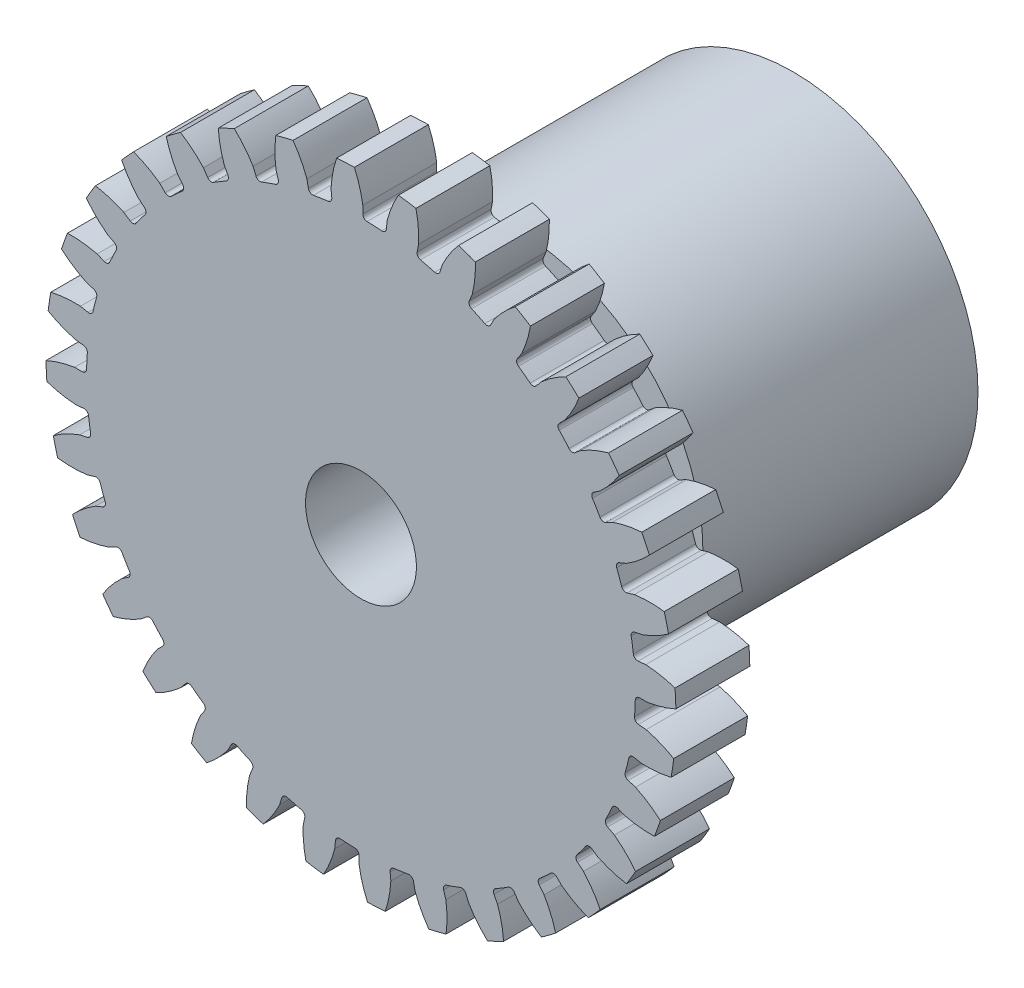
from build123d import *

# Parameters (mm, degrees)
SKETCH1_R                = 27.051
BOSS_EXTRUDE1_DEPTH      = 6.35
CUT_EXTRUDE1_DEPTH       = 7.35
FILLET1_R                = 0.37404675
CIRPATTERN1_COUNT        = 32
FILLET1_OF_CIRPATTERN1_R = 0.37404675
SKETCH5_R                = 11.1125
BOSS_EXTRUDE2_DEPTH      = 7.14375
SKETCH6_R                = 15.875
BOSS_EXTRUDE3_DEPTH      = 23.622
SKETCH7_R                = 4.7625
CUT_EXTRUDE2_DEPTH       = 38.1157501


with BuildPart() as part:
    # Sketch1 → Boss-Extrude1 (new body)
    with BuildSketch(Plane.XY):
        Circle(SKETCH1_R)
    extrude(amount=-BOSS_EXTRUDE1_DEPTH)

    # Sketch4 → Cut-Extrude1 (cut, through all)
    with BuildSketch(Plane.XY):
        with BuildLine():
            Line((0.160263574, 24.590427827), (0.160263574, 23.562717484))
            ThreePointArc((0.160263574, 23.562717484), (1.156197192, 23.534879386), (2.150063712, 23.464964643))
            Line((2.150063712, 23.464964643), (2.250797176, 24.487726256))
            add(Edge.make_bspline(
                [(5.408974443, 29.500900756), (2.99125855, 27.376376247), (2.250797176, 24.487726256)],
                knots=[0, 0, 0, 1, 1, 1], degree=2))
            ThreePointArc((5.408974443, 29.500900756), (1.471673918, 29.956540618), (-2.491327962, 29.889018634))
            add(Edge.make_bspline(
                [(-2.491327962, 29.889018634), (-0.293494388, 27.537746189), (0.160263574, 24.590427827)],
                knots=[0, 0, 0, 1, 1, 1], degree=2))
        make_face()
    cut_extrude1 = extrude(amount=-CUT_EXTRUDE1_DEPTH, mode=Mode.SUBTRACT)

    # Fillet1
    fillet1_edges = [part.edges().sort_by_distance(p)[0] for p in [
        (2.150063712, 23.464964643, -3.175),
        (0.160263574, 23.562717484, -3.175),
    ]]
    fillet(fillet1_edges, radius=FILLET1_R)

    # CirPattern1: Cut-Extrude1 ×32 about axis
    cirpattern1_axis = Axis((0, 0, -6.35), (0, 0, 1))
    for i in range(1, CIRPATTERN1_COUNT):
        add(cut_extrude1.rotate(cirpattern1_axis, i * 360 / CIRPATTERN1_COUNT), mode=Mode.SUBTRACT)

    # Fillet1 of CirPattern1
    fillet1_of_cirpattern1_edges = [part.edges().sort_by_distance(p)[0] for p in [
        (-2.469036668, 23.433548549, -3.175),
        (-4.439673987, 23.141232347, -3.175),
        (-6.993253353, 22.501594325, -3.175),
        (-8.868997367, 21.830442628, -3.175),
        (-11.248723233, 20.704916452, -3.175),
        (-12.957490151, 19.680721242, -3.175),
        (-15.071910988, 18.11256025, -3.175),
        (-16.548033856, 16.774680776, -3.175),
        (-18.315893657, 14.824148515, -3.175),
        (-19.5026459, 13.223998735, -3.175),
        (-20.856006803, 10.966053067, -3.175),
        (-21.707782199, 9.165125839, -3.175),
        (-22.594635305, 6.686538349, -3.175),
        (-23.078700602, 4.754042296, -3.175),
        (-23.464964643, 2.150063712, -3.175),
        (-23.562717484, 0.160263574, -3.175),
        (-23.433548549, -2.469036668, -3.175),
        (-23.141232347, -4.439673987, -3.175),
        (-22.501594325, -6.993253353, -3.175),
        (-21.830442628, -8.868997367, -3.175),
        (-20.704916452, -11.248723233, -3.175),
        (-19.680721242, -12.957490151, -3.175),
        (-18.11256025, -15.071910988, -3.175),
        (-16.774680776, -16.548033856, -3.175),
        (-14.824148515, -18.315893657, -3.175),
        (-13.223998735, -19.5026459, -3.175),
        (-10.966053067, -20.856006803, -3.175),
        (-9.165125839, -21.707782199, -3.175),
        (-6.686538349, -22.594635305, -3.175),
        (-4.754042296, -23.078700602, -3.175),
        (-2.150063712, -23.464964643, -3.175),
        (-0.160263574, -23.562717484, -3.175),
        (2.469036668, -23.433548549, -3.175),
        (4.439673987, -23.141232347, -3.175),
        (6.993253353, -22.501594325, -3.175),
        (8.868997367, -21.830442628, -3.175),
        (11.248723233, -20.704916452, -3.175),
        (12.957490151, -19.680721242, -3.175),
        (15.071910988, -18.11256025, -3.175),
        (16.548033856, -16.774680776, -3.175),
        (18.315893657, -14.824148515, -3.175),
        (19.5026459, -13.223998735, -3.175),
        (20.856006803, -10.966053067, -3.175),
        (21.707782199, -9.165125839, -3.175),
        (22.594635305, -6.686538349, -3.175),
        (23.078700602, -4.754042296, -3.175),
        (23.464964643, -2.150063712, -3.175),
        (23.562717484, -0.160263574, -3.175),
        (23.433548549, 2.469036668, -3.175),
        (23.141232347, 4.439673987, -3.175),
        (22.501594325, 6.993253353, -3.175),
        (21.830442628, 8.868997367, -3.175),
        (20.704916452, 11.248723233, -3.175),
        (19.680721242, 12.957490151, -3.175),
        (18.11256025, 15.071910988, -3.175),
        (16.774680776, 16.548033856, -3.175),
        (14.824148515, 18.315893657, -3.175),
        (13.223998735, 19.5026459, -3.175),
        (10.966053067, 20.856006803, -3.175),
        (9.165125839, 21.707782199, -3.175),
        (6.686538349, 22.594635305, -3.175),
        (4.754042296, 23.078700602, -3.175),
    ]]
    fillet(fillet1_of_cirpattern1_edges, radius=FILLET1_OF_CIRPATTERN1_R)

    # Sketch5 → Boss-Extrude2 (add)
    with BuildSketch(Plane(origin=(0, 0, -6.35), x_dir=(-1, 0, 0), z_dir=(0, 0, -1))):
        Circle(SKETCH5_R)
    extrude(amount=BOSS_EXTRUDE2_DEPTH)

    # Sketch6 → Boss-Extrude3 (add)
    with BuildSketch(Plane(origin=(0, 0, -13.49375), x_dir=(-1, 0, 0), z_dir=(0, 0, -1))):
        Circle(SKETCH6_R)
    extrude(amount=BOSS_EXTRUDE3_DEPTH)

    # Sketch7 → Cut-Extrude2 (cut, through all)
    with BuildSketch(Plane(origin=(0, 0, -37.11575), x_dir=(-1, 0, 0), z_dir=(0, 0, -1))):
        Circle(SKETCH7_R)
    extrude(amount=-CUT_EXTRUDE2_DEPTH, mode=Mode.SUBTRACT)


solid = part.part
